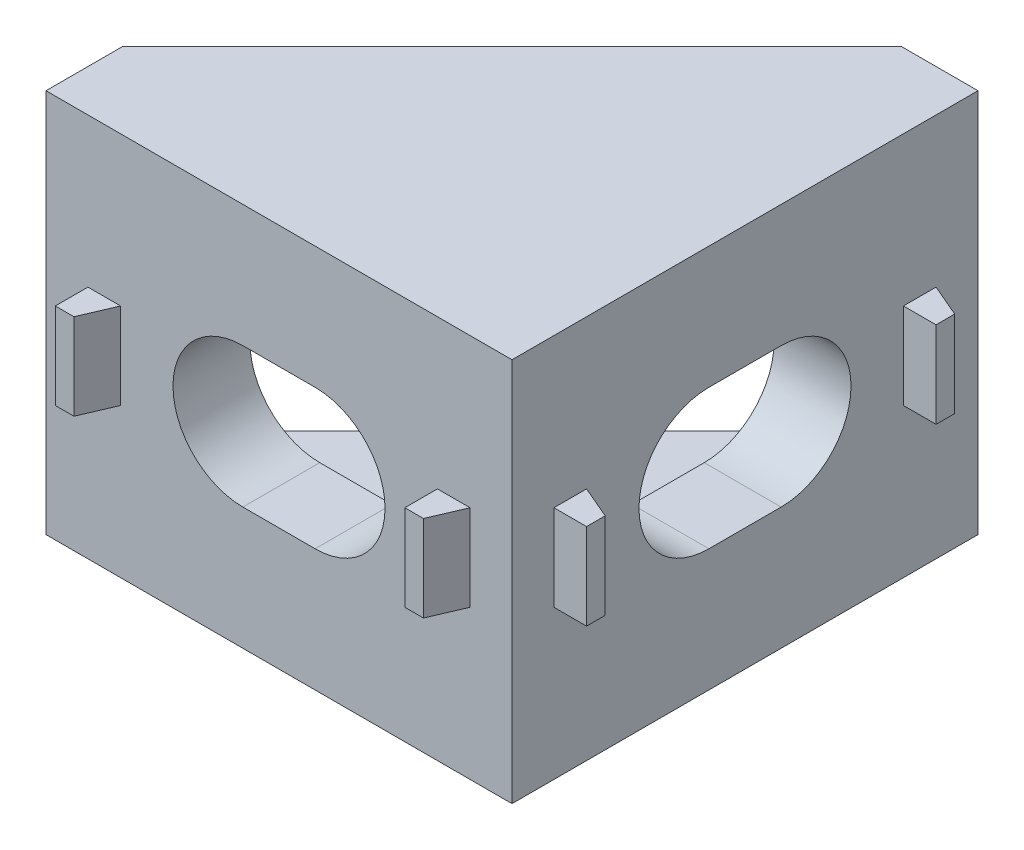
from build123d import *

# Parameters (mm, degrees)
CROQUIS1_W              = 20
CROQUIS1_H              = 16.5
SALIENTE_EXTRUIR1_DEPTH = 3.3
CROQUIS2_W              = 1.4
CROQUIS2_H              = 3.7
SALIENTE_EXTRUIR2_DEPTH = 1.4
CORTAR_EXTRUIR1_DEPTH   = 3.7
CORTAR_EXTRUIR2_DEPTH   = 3.7
CROQUIS6_W              = 20
CROQUIS6_H              = 16.5
SALIENTE_EXTRUIR3_DEPTH = 3.3
CROQUIS7_W              = 1.4
CROQUIS7_H              = 3.7
SALIENTE_EXTRUIR4_DEPTH = 1.4
CORTAR_EXTRUIR3_DEPTH   = 3.7
CORTAR_EXTRUIR4_DEPTH   = 3.7
SALIENTE_EXTRUIR5_DEPTH = 2.2
SALIENTE_EXTRUIR6_DEPTH = 2.2


with BuildPart() as part:
    # Croquis1 → Saliente-Extruir1 (new body)
    with BuildSketch(Plane.XY):
        Rectangle(CROQUIS1_W, CROQUIS1_H)
        with BuildLine():
            Line((-1.55, 3), (1.55, 3))
            ThreePointArc((1.55, 3), (4.55, 0), (1.55, -3))
            Line((1.55, -3), (-1.55, -3))
            ThreePointArc((-1.55, -3), (-4.55, 0), (-1.55, 3))
        make_face(mode=Mode.SUBTRACT)
    extrude(amount=SALIENTE_EXTRUIR1_DEPTH)

    # Croquis2 → Saliente-Extruir2 (add)
    with BuildSketch(Plane.XY.offset(3.3)):
        with Locations((-7.5, 0)):
            Rectangle(CROQUIS2_W, CROQUIS2_H)
        with Locations((7.5, 0)):
            Rectangle(CROQUIS2_W, CROQUIS2_H)
    extrude(amount=SALIENTE_EXTRUIR2_DEPTH)

    # Croquis4 → Cortar-Extruir1 (cut)
    with BuildSketch(Plane.XZ.offset(1.85)):
        Polygon((8.2, 3.3), (7.6, 4.7), (8.2, 4.7), align=None)
    extrude(amount=-CORTAR_EXTRUIR1_DEPTH, mode=Mode.SUBTRACT)

    # Croquis5 → Cortar-Extruir2 (cut)
    with BuildSketch(Plane.XZ.offset(1.85)):
        Polygon((-6.8, 3.3), (-7.4, 4.7), (-6.8, 4.7), align=None)
    extrude(amount=-CORTAR_EXTRUIR2_DEPTH, mode=Mode.SUBTRACT)

    # Croquis6 → Saliente-Extruir3 (add)
    with BuildSketch(Plane(origin=(10, 0, 0), x_dir=(0, 0, -1), z_dir=(1, 0, 0))):
        with Locations((6.7, 0)):
            Rectangle(CROQUIS6_W, CROQUIS6_H)
        with BuildLine():
            Line((5.15, 3), (8.25, 3))
            ThreePointArc((8.25, 3), (11.25, 0), (8.25, -3))
            Line((8.25, -3), (5.15, -3))
            ThreePointArc((5.15, -3), (2.15, 0), (5.15, 3))
        make_face(mode=Mode.SUBTRACT)
    extrude(amount=-SALIENTE_EXTRUIR3_DEPTH)

    # Croquis7 → Saliente-Extruir4 (add)
    with BuildSketch(Plane(origin=(10, 0, 0), x_dir=(0, 0, -1), z_dir=(1, 0, 0))):
        with Locations((-0.8, 0)):
            Rectangle(CROQUIS7_W, CROQUIS7_H)
        with Locations((14.2, 0)):
            Rectangle(CROQUIS7_W, CROQUIS7_H)
    extrude(amount=SALIENTE_EXTRUIR4_DEPTH)

    # Croquis11 → Cortar-Extruir3 (cut)
    with BuildSketch(Plane.XZ.offset(1.85)):
        Polygon((11.4, 0.1), (10, 0.1), (11.4, 0.7), align=None)
    extrude(amount=-CORTAR_EXTRUIR3_DEPTH, mode=Mode.SUBTRACT)

    # Croquis12 → Cortar-Extruir4 (cut)
    with BuildSketch(Plane.XZ.offset(1.85)):
        Polygon((11.4, -14.9), (10, -14.9), (11.4, -14.3), align=None)
    extrude(amount=-CORTAR_EXTRUIR4_DEPTH, mode=Mode.SUBTRACT)

    # Croquis13 → Saliente-Extruir5 (add)
    with BuildSketch(Plane(origin=(0, -8.25, 0), x_dir=(-1, 0, 0), z_dir=(0, -1, 0))):
        Polygon((-6.7, 16.7), (10, 0), (-6.7, 0), align=None)
    extrude(amount=-SALIENTE_EXTRUIR5_DEPTH)

    # Croquis14 → Saliente-Extruir6 (add)
    with BuildSketch(Plane(origin=(0, 8.25, 0), x_dir=(1, 0, 0), z_dir=(0, 1, 0))):
        Polygon((6.7, 16.7), (-10, 0), (6.7, 0), align=None)
    extrude(amount=-SALIENTE_EXTRUIR6_DEPTH)


solid = part.part
